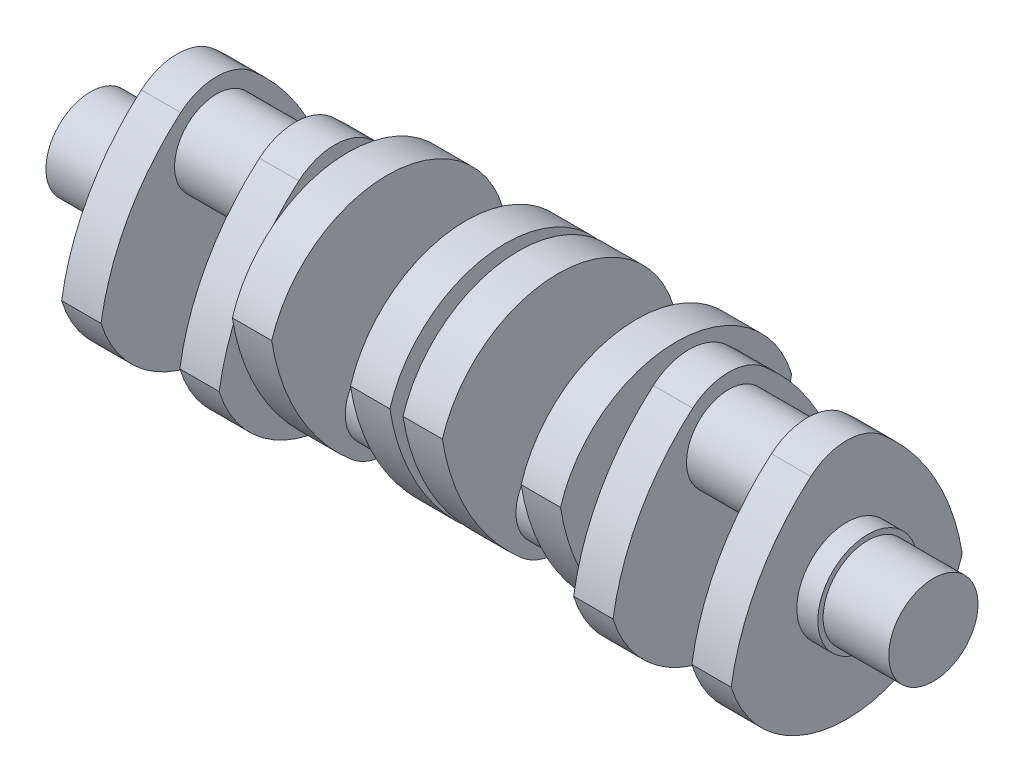
from build123d import *

# Parameters (mm, degrees)
SKETCH1_R           = 431.8
BOSS_EXTRUDE1_DEPTH = 635
SKETCH1_3_R         = 482.6
BOSS_EXTRUDE2_DEPTH = 203.2
BOSS_EXTRUDE3_DEPTH = 381
SKETCH3_R           = 406.4
BOSS_EXTRUDE4_DEPTH = 381
BOSS_EXTRUDE5_START = 127
SKETCH4_R           = 431.8
BOSS_EXTRUDE5_DEPTH = 127
BOSS_EXTRUDE6_DEPTH = 381
SKETCH6_R           = 406.4
BOSS_EXTRUDE7_DEPTH = 762
BOSS_EXTRUDE8_DEPTH = 381
BOSS_EXTRUDE9_START = 63.5
SKETCH8_R           = 431.8
BOSS_EXTRUDE9_DEPTH = 63.5


with BuildPart() as part:
    # Sketch1 → Boss-Extrude1 (new body)
    with BuildSketch(Plane(origin=(0, 0, 0), x_dir=(0, 0, -1), z_dir=(1, 0, 0))):
        Circle(SKETCH1_R)
    extrude(amount=-BOSS_EXTRUDE1_DEPTH)

    # Sketch1_3 → Boss-Extrude2 (add)
    with BuildSketch(Plane(origin=(0, 0, 0), x_dir=(0, 0, -1), z_dir=(1, 0, 0))):
        Circle(SKETCH1_3_R)
    extrude(amount=BOSS_EXTRUDE2_DEPTH)

    # Sketch2 → Boss-Extrude3 (add)
    with BuildSketch(Plane(origin=(203.2, 0, 0), x_dir=(0, 0, -1), z_dir=(1, 0, 0))):
        with BuildLine():
            ThreePointArc((-347.169606843, 1039.955335913), (0, 1168.4), (347.169606843, 1039.955335913))
            ThreePointArc((347.169606843, 1039.955335913), (855.559483917, 418.319143644), (1117.6, -340.776759771))
            ThreePointArc((1117.6, -340.776759771), (0, -1168.4), (-1117.6, -340.776759771))
            ThreePointArc((-1117.6, -340.776759771), (-855.559483917, 418.319143644), (-347.169606843, 1039.955335913))
        make_face()
    boss_extrude3 = extrude(amount=BOSS_EXTRUDE3_DEPTH)

    # Sketch3 → Boss-Extrude4 (add)
    with BuildSketch(Plane(origin=(584.2, 0, 0), x_dir=(0, 0, -1), z_dir=(1, 0, 0))):
        with Locations((0, 616.197244193)):
            Circle(SKETCH3_R)
    boss_extrude4 = extrude(amount=BOSS_EXTRUDE4_DEPTH)

    # Mirror2: Boss-Extrude3, Boss-Extrude4 across plane
    add(boss_extrude3.mirror(Plane(origin=(965.2, 616.197244193, 0), x_dir=(0, 0, 1), z_dir=(1, 0, 0))))
    add(boss_extrude4.mirror(Plane(origin=(965.2, 616.197244193, 0), x_dir=(0, 0, 1), z_dir=(1, 0, 0))))

    # Sketch4 → Boss-Extrude5 (add)
    with BuildSketch(Plane(origin=(1727.2, 0, 0), x_dir=(0, 0, -1), z_dir=(1, 0, 0)).offset(BOSS_EXTRUDE5_START)):
        Circle(SKETCH4_R)
    extrude(amount=-BOSS_EXTRUDE5_DEPTH)

    # Sketch5 → Boss-Extrude6 (add)
    with BuildSketch(Plane(origin=(1854.2, 0, 0), x_dir=(0, 0, -1), z_dir=(1, 0, 0))):
        with BuildLine():
            ThreePointArc((-347.169606843, -1039.955335913), (0, -1168.4), (347.169606843, -1039.955335913))
            ThreePointArc((347.169606843, -1039.955335913), (855.559483917, -418.319143644), (1117.6, 340.776759771))
            ThreePointArc((1117.6, 340.776759771), (0, 1168.4), (-1117.6, 340.776759771))
            ThreePointArc((-1117.6, 340.776759771), (-855.559483917, -418.319143644), (-347.169606843, -1039.955335913))
        make_face()
    extrude(amount=BOSS_EXTRUDE6_DEPTH)

    # Sketch6 → Boss-Extrude7 (add)
    with BuildSketch(Plane(origin=(2235.2, 0, 0), x_dir=(0, 0, -1), z_dir=(1, 0, 0))):
        with Locations((0, -635)):
            Circle(SKETCH6_R)
    extrude(amount=BOSS_EXTRUDE7_DEPTH)

    # Sketch7 → Boss-Extrude8 (add)
    with BuildSketch(Plane(origin=(2997.2, 0, 0), x_dir=(0, 0, -1), z_dir=(1, 0, 0))):
        with BuildLine():
            ThreePointArc((-347.169606843, -1039.955335913), (0, -1168.4), (347.169606843, -1039.955335913))
            ThreePointArc((347.169606843, -1039.955335913), (855.559483917, -418.319143644), (1117.6, 340.776759771))
            ThreePointArc((1117.6, 340.776759771), (0, 1168.4), (-1117.6, 340.776759771))
            ThreePointArc((-1117.6, 340.776759771), (-855.559483917, -418.319143644), (-347.169606843, -1039.955335913))
        make_face()
    extrude(amount=BOSS_EXTRUDE8_DEPTH)

    # Sketch8 → Boss-Extrude9 (add)
    with BuildSketch(Plane(origin=(3378.2, 0, 0), x_dir=(0, 0, -1), z_dir=(1, 0, 0)).offset(BOSS_EXTRUDE9_START)):
        Circle(SKETCH8_R)
    extrude(amount=-BOSS_EXTRUDE9_DEPTH)

    # Mirror3: part across plane


with BuildPart() as part_1:
    add(part.part)
    add(part.part.mirror(Plane(origin=(3441.7, 0, 0), x_dir=(0, 0, 1), z_dir=(1, 0, 0))))


solid = part_1.part
